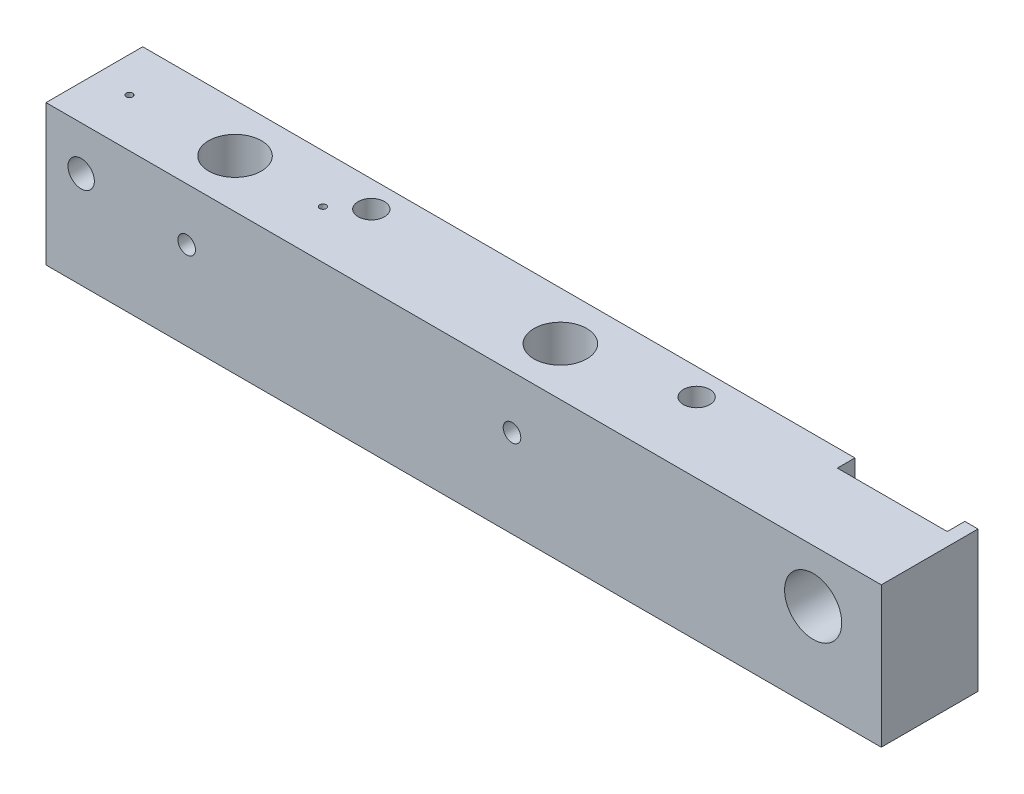
from build123d import *

# Parameters (mm, degrees)
SKETCH2_W           = 190
SKETCH2_H           = 22
BOSS_EXTRUDE1_DEPTH = 32
SKETCH3_R           = 0.75
SKETCH3_R_2         = 6
SKETCH3_R_3         = 3
SKETCH3_W           = 25
SKETCH3_H           = 4
CUT_EXTRUDE1_DEPTH  = 24
SKETCH4_W           = 25
SKETCH4_H           = 4
CUT_EXTRUDE2_DEPTH  = 9
SKETCH5_R           = 3
SKETCH5_R_2         = 2
SKETCH5_R_3         = 6.5
CUT_EXTRUDE3_DEPTH  = 24


with BuildPart() as part:
    # Sketch2 → Boss-Extrude1 (new body)
    with BuildSketch(Plane(origin=(0, 0, 0), x_dir=(1, 0, 0), z_dir=(0, 1, 0))):
        Rectangle(SKETCH2_W, SKETCH2_H)
    extrude(amount=BOSS_EXTRUDE1_DEPTH)

    # Sketch3 → Cut-Extrude1 (cut)
    with BuildSketch(Plane(origin=(0, 32, 0), x_dir=(1, 0, 0), z_dir=(0, 1, 0))):
        with Locations((-87, 0)):
            Circle(SKETCH3_R)
        with Locations((-63, 0)):
            Circle(SKETCH3_R_2)
        with Locations((-37, 5)):
            Circle(SKETCH3_R_3)
        with Locations((-43, 0)):
            Circle(SKETCH3_R)
        with Locations((11, 0)):
            Circle(SKETCH3_R_2)
        with Locations((37, 5)):
            Circle(SKETCH3_R_3)
        with Locations((79.5, 9)):
            Rectangle(SKETCH3_W, SKETCH3_H)
    extrude(amount=-CUT_EXTRUDE1_DEPTH, mode=Mode.SUBTRACT)

    # Sketch4 → Cut-Extrude2 (cut, through all)
    with BuildSketch(Plane(origin=(0, 8, 0), x_dir=(1, 0, 0), z_dir=(0, 1, 0))):
        with Locations((79.5, 9)):
            Rectangle(SKETCH4_W, SKETCH4_H)
    extrude(amount=-CUT_EXTRUDE2_DEPTH, mode=Mode.SUBTRACT)

    # Sketch5 → Cut-Extrude3 (cut)
    with BuildSketch(Plane.XY.offset(11)):
        with Locations((-87, 22)):
            Circle(SKETCH5_R)
        with Locations((-63, 20)):
            Circle(SKETCH5_R_2)
        with Locations((11, 20)):
            Circle(SKETCH5_R_2)
        with Locations((79.5, 20)):
            Circle(SKETCH5_R_3)
    extrude(amount=-CUT_EXTRUDE3_DEPTH, mode=Mode.SUBTRACT)


solid = part.part
